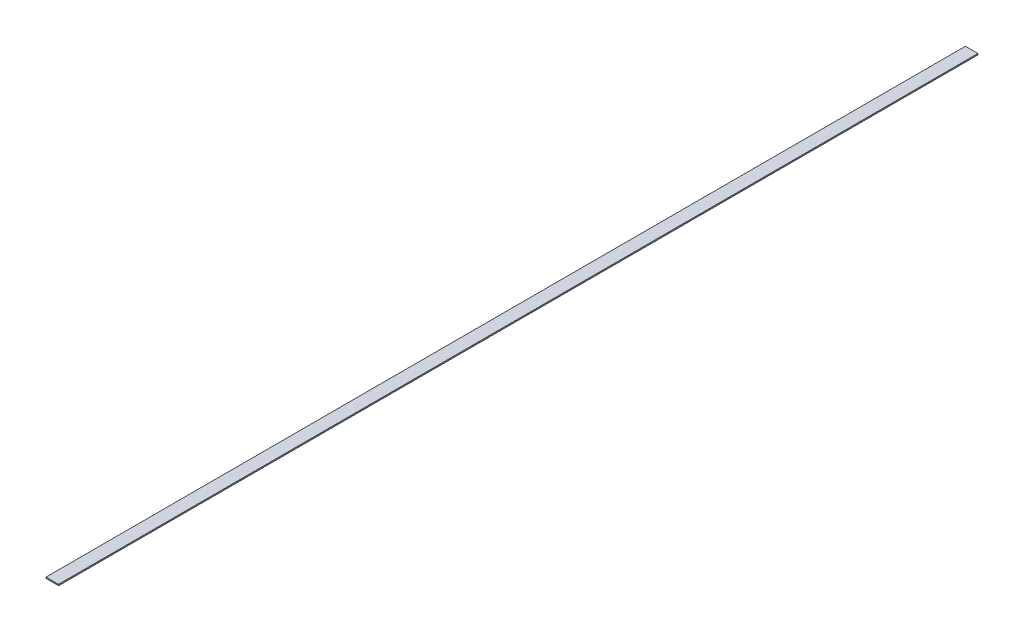
from build123d import *

# Parameters (mm, degrees)
SKETCH1_W           = 50.8
SKETCH1_H           = 3721.1
BOSS_EXTRUDE1_DEPTH = 5.08


with BuildPart() as part:
    # Sketch1 → Boss-Extrude1 (new body)
    with BuildSketch(Plane(origin=(0, 0, 0), x_dir=(1, 0, 0), z_dir=(0, 1, 0))):
        with Locations((-25.4, 1860.55)):
            Rectangle(SKETCH1_W, SKETCH1_H)
    extrude(amount=BOSS_EXTRUDE1_DEPTH)


solid = part.part
